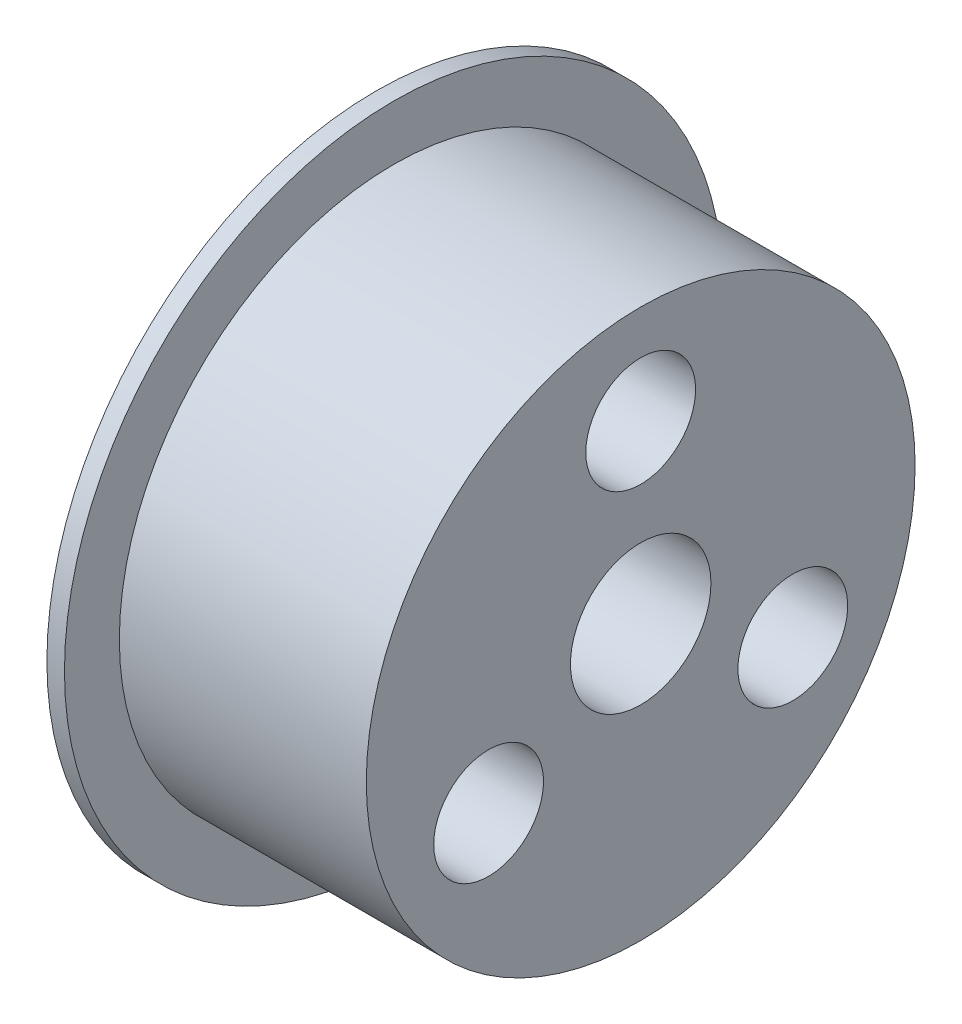
from build123d import *

# Parameters (mm, degrees)
F_1_4_0_2500_DOWEL_HOLE1_D = 6.35


with BuildPart() as part:
    # Sketch1 → Revolve1 (revolve)
    with BuildSketch(Plane.XY):
        Polygon((0, 4.064), (-15.3035, 4.064), (-15.3035, 19.05), (-14.2875, 19.05), (-14.2875, 15.875), (0, 15.875), align=None)
    revolve(axis=Axis((0, 0, 0), (-1, 0, 0)))

    # 1/4 (0.2500) Dowel Hole1 (through all)
    with Locations(Plane.ZY.offset(15.3035)):
        with Locations((0, 10.16), (8.798818102, -5.08), (-8.798818102, -5.08)):
            Hole(F_1_4_0_2500_DOWEL_HOLE1_D / 2)


solid = part.part
